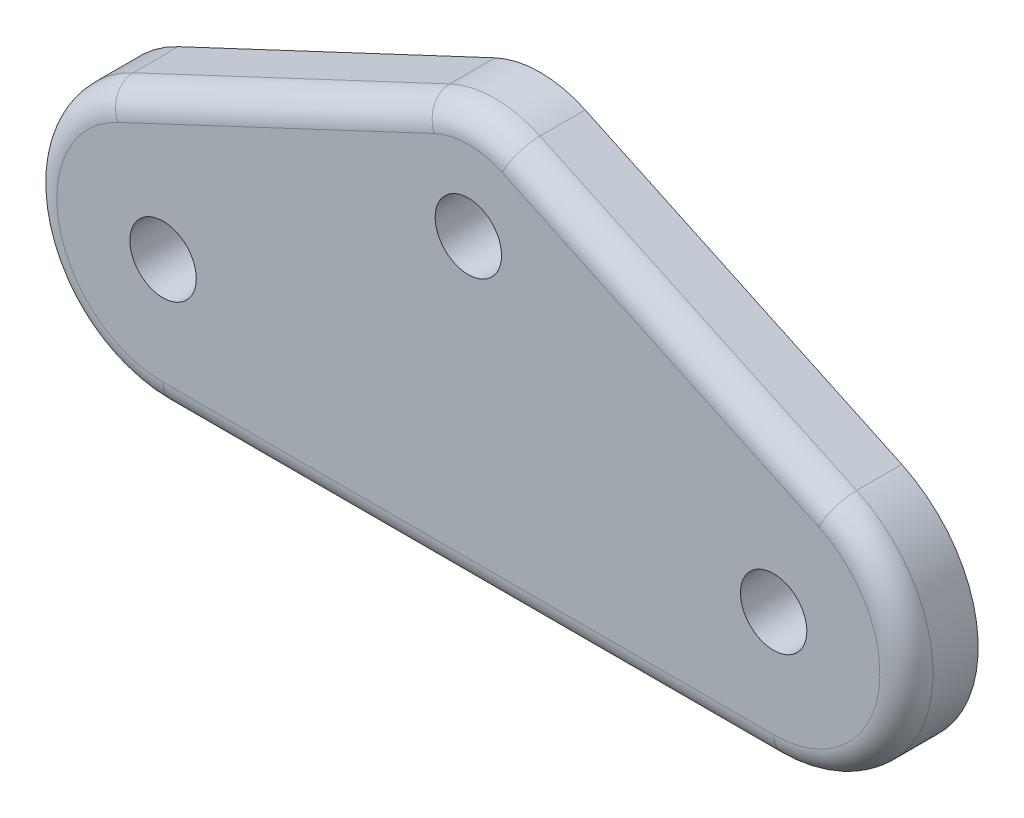
from build123d import *

# Parameters (mm, degrees)
BOSS_EXTRUDE1_DEPTH        = 3.429
FILLET1_R                  = 1.27
F_1_8_0_1250_DOWEL_HOLE1_D = 3.175


with BuildPart() as part:
    # Sketch2 → Boss-Extrude1 (new body)
    with BuildSketch(Plane.XY):
        with BuildLine():
            Line((-17.292487403, 5.747971587), (-2.159010534, 12.853377269))
            ThreePointArc((-2.159010534, 12.853377269), (0, 13.335), (2.159010534, 12.853377269))
            Line((2.159010534, 12.853377269), (17.292487403, 5.747971587))
            ThreePointArc((17.292487403, 5.747971587), (20.791389907, -1.382548448), (14.593724234, -6.35))
            Line((14.593724234, -6.35), (-14.593724234, -6.35))
            ThreePointArc((-14.593724234, -6.35), (-20.791389907, -1.382548448), (-17.292487403, 5.747971587))
        make_face()
    extrude(amount=BOSS_EXTRUDE1_DEPTH)

    # Fillet1
    fillet1_edges = [part.edges().sort_by_distance(p)[0] for p in [
        (20.791389907, -1.382548448, 3.429),
        (9.725748968, 9.300674428, 3.429),
        (0, 13.335, 3.429),
        (-9.725748968, 9.300674428, 3.429),
        (-20.791389907, -1.382548448, 3.429),
        (0, -6.35, 3.429),
    ]]
    fillet(fillet1_edges, radius=FILLET1_R)

    # 1/8 (0.1250) Dowel Hole1 (through all)
    with Locations(Plane.XY.offset(3.429)):
        with Locations((0, 8.255), (-14.593724234, 0), (14.593724234, 0)):
            Hole(F_1_8_0_1250_DOWEL_HOLE1_D / 2)


solid = part.part
